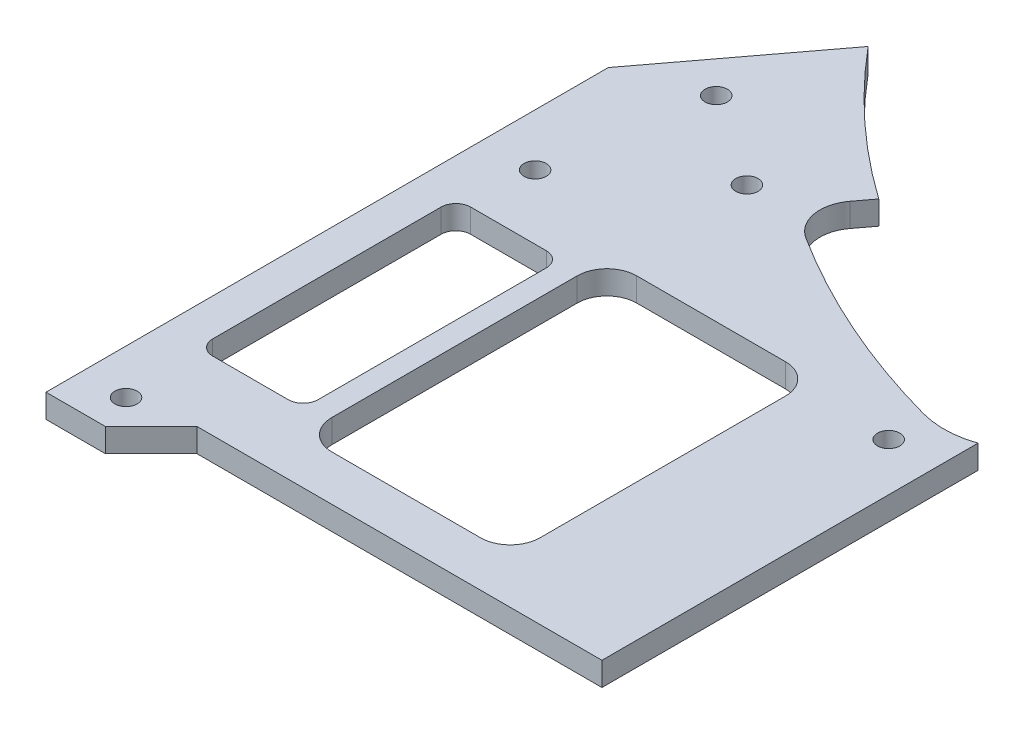
from build123d import *

# Parameters (mm, degrees)
SKETCH1_R                    = 7
SKETCH1_R_2                  = 3.9
SKETCH1_R_3                  = 1.3
SKETCH1_W                    = 14.16
SKETCH1_H                    = 34.693281024
BOSS_EXTRUDE1_DEPTH          = 3.175
FILLET1_R                    = 2
SKETCH2_R                    = 1.5
CUT_EXTRUDE1_DEPTH           = 4.175
SKETCH5_W                    = 28
SKETCH5_H                    = 41
CUT_EXTRUDE3_DEPTH           = 4.175
FILLET2_R                    = 4
SKETCH10_R                   = 1.5
NOSE_GUARD_SCREW_HOLES_DEPTH = 4.175
SKETCH11_R                   = 20
CUT_EXTRUDE4_DEPTH           = 4.175
SKETCH12_R                   = 1.5
CUT_EXTRUDE5_DEPTH           = 4.175
SKETCH13_R                   = 96.550525729
CUT_EXTRUDE6_DEPTH           = 4.175
SKETCH14_W                   = 292.522671741
SKETCH14_H                   = 256.088396318
CUT_EXTRUDE7_DEPTH           = 4.175


with BuildPart() as part:
    # Sketch1 → Boss-Extrude1 (new body)
    with BuildSketch(Plane(origin=(0, 32.825, 0), x_dir=(1, 0, 0), z_dir=(0, 1, 0))):
        with BuildLine():
            Line((89.16, -81.763233191), (17.569981221, 13.239930509))
            ThreePointArc((17.569981221, 13.239930509), (0, 22), (-17.569981221, 13.239930509))
            Line((-17.569981221, 13.239930509), (-89.16, -81.763233191))
            Line((-89.16, -81.763233191), (-89.16, -157.357359313))
            Line((-89.16, -157.357359313), (-81.189437252, -157.357359313))
            Line((-81.189437252, -157.357359313), (-75.032077939, -151.2))
            Line((-75.032077939, -151.2), (75.032077939, -151.2))
            Line((75.032077939, -151.2), (81.189437252, -157.357359313))
            Line((81.189437252, -157.357359313), (89.16, -157.357359313))
            Line((89.16, -157.357359313), (89.16, -81.763233191))
        make_face()
        with Locations((0, -124.6)):
            Circle(SKETCH1_R, mode=Mode.SUBTRACT)
        Circle(SKETCH1_R_2, mode=Mode.SUBTRACT)
        with Locations((0, -28)):
            Circle(SKETCH1_R_3, mode=Mode.SUBTRACT)
        with Locations((-77.08, -124.6)):
            Rectangle(SKETCH1_W, SKETCH1_H, mode=Mode.SUBTRACT)
        with Locations((77.08, -124.6)):
            Rectangle(SKETCH1_W, SKETCH1_H, mode=Mode.SUBTRACT)
        with BuildLine():
            Line((-21.49317755, -33.507330392), (-57.351202685, -81.09253696))
            ThreePointArc((-57.351202685, -81.09253696), (-58.277395442, -84.995925096), (-56.036640854, -88.323580553))
            ThreePointArc((-56.036640854, -88.323580553), (-42.323470644, -95.65502513), (-27.674946004, -100.872480705))
            ThreePointArc((-27.674946004, -100.872480705), (-17.223302674, -98.842107372), (-12.5, -89.300111982))
            Line((-12.5, -89.300111982), (-12.5, -36.516405507))
            ThreePointArc((-12.5, -36.516405507), (-15.913476718, -31.774787231), (-21.49317755, -33.507330392))
        make_face(mode=Mode.SUBTRACT)
        with BuildLine():
            Line((57.351202685, -81.09253696), (21.49317755, -33.507330392))
            ThreePointArc((21.49317755, -33.507330392), (15.913476718, -31.774787231), (12.5, -36.516405507))
            Line((12.5, -36.516405507), (12.5, -89.300111982))
            ThreePointArc((12.5, -89.300111982), (17.223302674, -98.842107372), (27.674946004, -100.872480705))
            ThreePointArc((27.674946004, -100.872480705), (42.323470644, -95.65502513), (56.036640854, -88.323580553))
            ThreePointArc((56.036640854, -88.323580553), (58.277395442, -84.995925096), (57.351202685, -81.09253696))
        make_face(mode=Mode.SUBTRACT)
    extrude(amount=BOSS_EXTRUDE1_DEPTH)

    # Fillet1
    fillet1_edges = [part.edges().sort_by_distance(p)[0] for p in [
        (-84.16, 34.4125, 107.253359488),
        (-84.16, 34.4125, 141.946640512),
        (-70, 34.4125, 141.946640512),
        (-70, 34.4125, 107.253359488),
        (84.16, 34.4125, 107.253359488),
        (70, 34.4125, 107.253359488),
        (70, 34.4125, 141.946640512),
        (84.16, 34.4125, 141.946640512),
    ]]
    fillet(fillet1_edges, radius=FILLET1_R)

    # Sketch2 → Cut-Extrude1 (cut, through all)
    with BuildSketch(Plane(origin=(0, 36, 0), x_dir=(1, 0, 0), z_dir=(0, 1, 0))):
        with Locations((-62.088932188, -184.6)):
            Circle(SKETCH2_R)
        with Locations((-27, -106.222219898)):
            Circle(SKETCH2_R)
        with Locations((-83.16, -152.6)):
            Circle(SKETCH2_R)
        with Locations((-78.638732223, -77.770880118)):
            Circle(SKETCH2_R)
        with Locations((27, -106.222219898)):
            Circle(SKETCH2_R)
        with Locations((62.088932188, -184.6)):
            Circle(SKETCH2_R)
        with Locations((83.16, -162.114718626)):
            Circle(SKETCH2_R)
        with Locations((78.638732223, -77.770880118)):
            Circle(SKETCH2_R)
        with Locations((83.16, -152.6)):
            Circle(SKETCH2_R)
        with Locations((-83.16, -162.114718626)):
            Circle(SKETCH2_R)
    extrude(amount=-CUT_EXTRUDE1_DEPTH, mode=Mode.SUBTRACT)

    # Sketch5 → Cut-Extrude3 (cut, through all)
    with BuildSketch(Plane(origin=(0, 36, 0), x_dir=(1, 0, 0), z_dir=(0, 1, 0))):
        with Locations((-53, -124.6)):
            Rectangle(SKETCH5_W, SKETCH5_H)
        with Locations((53, -124.6)):
            Rectangle(SKETCH5_W, SKETCH5_H)
    extrude(amount=-CUT_EXTRUDE3_DEPTH, mode=Mode.SUBTRACT)

    # Fillet2
    fillet2_edges = [part.edges().sort_by_distance(p)[0] for p in [
        (-67, 34.4125, 145.1),
        (-67, 34.4125, 104.1),
        (-39, 34.4125, 104.1),
        (-39, 34.4125, 145.1),
        (67, 34.4125, 104.1),
        (67, 34.4125, 145.1),
        (39, 34.4125, 145.1),
        (39, 34.4125, 104.1),
    ]]
    fillet(fillet2_edges, radius=FILLET2_R)

    # Sketch10 → nose-guard-screw-holes (cut, through all)
    with BuildSketch(Plane(origin=(0, 36, 0), x_dir=(1, 0, 0), z_dir=(0, 1, 0))):
        with Locations((0, 17)):
            Circle(SKETCH10_R)
        with Locations((-14.722431864, 8.5)):
            Circle(SKETCH10_R)
        with Locations((14.722431864, 8.5)):
            Circle(SKETCH10_R)
        with Locations((0, -44.25832974)):
            Circle(SKETCH10_R)
        with Locations((0, -67.77856843)):
            Circle(SKETCH10_R)
        with Locations((0, -91.29880712)):
            Circle(SKETCH10_R)
    extrude(amount=-NOSE_GUARD_SCREW_HOLES_DEPTH, mode=Mode.SUBTRACT)

    # Sketch11 → Cut-Extrude4 (cut, through all)
    with BuildSketch(Plane(origin=(0, 36, 0), x_dir=(1, 0, 0), z_dir=(0, 1, 0))):
        with Locations((0, -124.6)):
            Circle(SKETCH11_R)
    extrude(amount=-CUT_EXTRUDE4_DEPTH, mode=Mode.SUBTRACT)

    # Sketch12 → Cut-Extrude5 (cut, through all)
    with BuildSketch(Plane(origin=(0, 36, 0), x_dir=(1, 0, 0), z_dir=(0, 1, 0))):
        with Locations((-82.16, -98.6)):
            Circle(SKETCH12_R)
        with Locations((66.171704332, -86.11193614)):
            Circle(SKETCH12_R)
        with Locations((82.16, -98.6)):
            Circle(SKETCH12_R)
        with Locations((-66.171704332, -86.11193614)):
            Circle(SKETCH12_R)
    extrude(amount=-CUT_EXTRUDE5_DEPTH, mode=Mode.SUBTRACT)

    # Sketch13 → Cut-Extrude6 (cut, through all)
    with BuildSketch(Plane(origin=(0, 36, 0), x_dir=(1, 0, 0), z_dir=(0, 1, 0))):
        Circle(SKETCH13_R)
    extrude(amount=-CUT_EXTRUDE6_DEPTH, mode=Mode.SUBTRACT)

    # Sketch14 → Cut-Extrude7 (cut, through all)
    with BuildSketch(Plane(origin=(0, 36, 0), x_dir=(1, 0, 0), z_dir=(0, 1, 0))):
        with Locations((125.685144355, -44.004038114)):
            Rectangle(SKETCH14_W, SKETCH14_H)
    extrude(amount=-CUT_EXTRUDE7_DEPTH, mode=Mode.SUBTRACT)


solid = part.part
